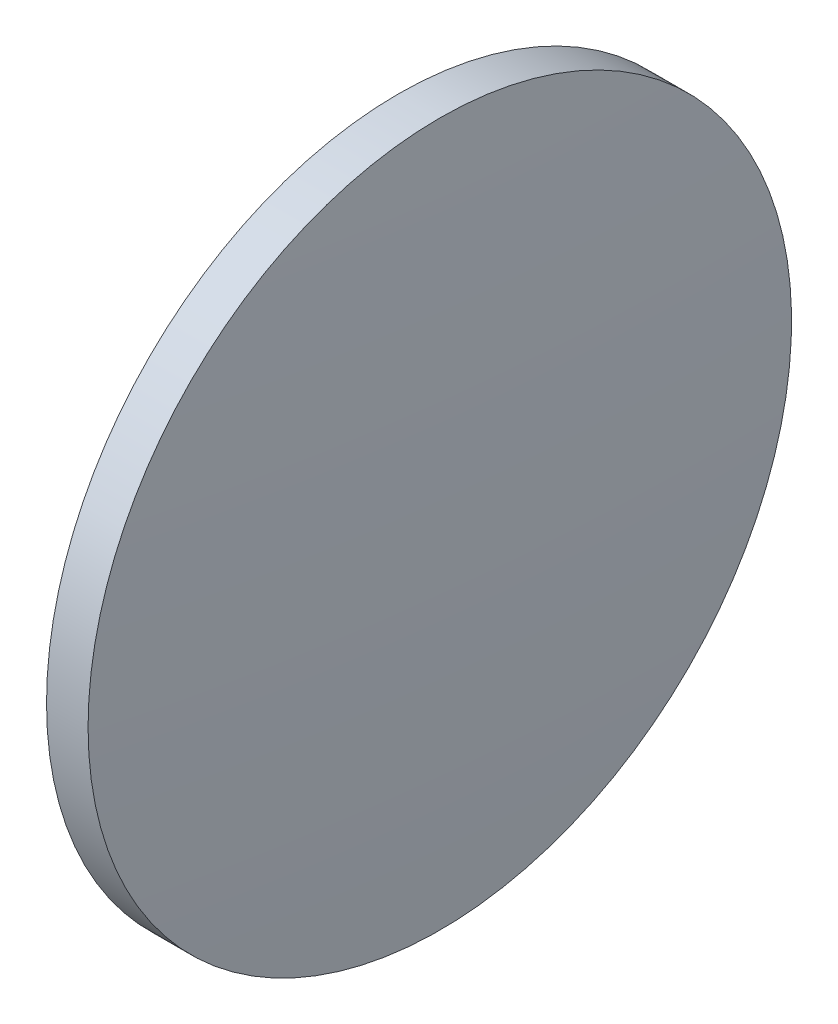
from build123d import *

# Parameters (mm, degrees)
SKETCH_1_ONE_SIDE_W = 2.999957714
SKETCH_1_ONE_SIDE_H = 25.4


with BuildPart() as part:
    # 草图1 one side → 旋转1 (revolve)
    with BuildSketch(Plane.XY):
        with Locations((172.916387549, 109.932226046)):
            Rectangle(SKETCH_1_ONE_SIDE_W, SKETCH_1_ONE_SIDE_H)
        with BuildLine():
            Line((170.716391949, 97.232226046), (171.416408692, 97.232226046))
            Line((171.416408692, 97.232226046), (171.416408692, 122.632226046))
            ThreePointArc((171.416408692, 122.632226046), (170.891429353, 109.937048196), (170.716391949, 97.232226046))
        make_face()
        with BuildLine():
            Line((174.416366406, 97.232226046), (175.116383149, 97.232226046))
            ThreePointArc((175.116383149, 97.232226046), (174.941345746, 109.937048196), (174.416366406, 122.632226046))
            Line((174.416366406, 122.632226046), (174.416366406, 97.232226046))
        make_face()
    revolve(axis=Axis((165.744107942, 97.232226046, 0), (1, 0, 0)))


solid = part.part
